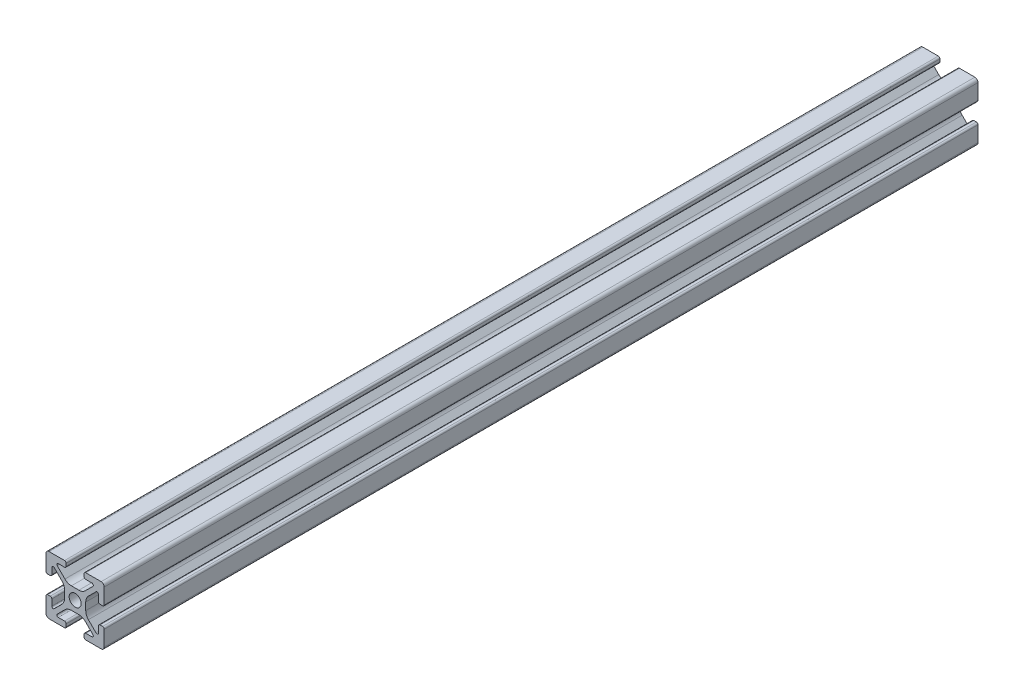
from build123d import *

# Parameters (mm, degrees)
SKETCH2_R           = 2.05
BOSS_EXTRUDE1_DEPTH = 300


with BuildPart() as part:
    # Sketch2 → Boss-Extrude1 (new body)
    with BuildSketch(Plane.XY):
        with BuildLine():
            Line((-3.642230561, 1.287773026), (-3.642230561, -1.287773026))
            ThreePointArc((-3.642230561, -1.287773026), (-3.87999308, -2.483085929), (-4.55708345, -3.496423279))
            Line((-4.55708345, -3.496423279), (-7.182004606, -6.121344434))
            ThreePointArc((-7.182004606, -6.121344434), (-7.704200045, -6.225215565), (-8, -5.782519648))
            Line((-8, -5.782519648), (-8, -3.622007668))
            ThreePointArc((-8, -3.622007668), (-8.161974206, -3.230967343), (-8.553014531, -3.068993137))
            Line((-8.553014531, -3.068993137), (-9.443284204, -3.068993137))
            ThreePointArc((-9.443284204, -3.068993137), (-9.836715763, -3.229656566), (-10, -3.622007668))
            Line((-10, -3.622007668), (-10, -8.939033256))
            ThreePointArc((-10, -8.939033256), (-9.689250035, -9.689250035), (-8.939033256, -10))
            Line((-8.939033256, -10), (-3.622007668, -10))
            ThreePointArc((-3.622007668, -10), (-3.229656566, -9.836715763), (-3.068993137, -9.443284204))
            Line((-3.068993137, -9.443284204), (-3.068993137, -8.553014531))
            ThreePointArc((-3.068993137, -8.553014531), (-3.230967343, -8.161974206), (-3.622007668, -8))
            Line((-3.622007668, -8), (-5.782519648, -8))
            ThreePointArc((-5.782519648, -8), (-6.225215565, -7.704200045), (-6.121344434, -7.182004606))
            Line((-6.121344434, -7.182004606), (-3.496423279, -4.55708345))
            ThreePointArc((-3.496423279, -4.55708345), (-2.483085929, -3.87999308), (-1.287773026, -3.642230561))
            Line((-1.287773026, -3.642230561), (1.287773026, -3.642230561))
            ThreePointArc((1.287773026, -3.642230561), (2.483085929, -3.87999308), (3.496423279, -4.55708345))
            Line((3.496423279, -4.55708345), (6.121344434, -7.182004606))
            ThreePointArc((6.121344434, -7.182004606), (6.225215565, -7.704200045), (5.782519648, -8))
            Line((5.782519648, -8), (3.622007668, -8))
            ThreePointArc((3.622007668, -8), (3.230967343, -8.161974206), (3.068993137, -8.553014531))
            Line((3.068993137, -8.553014531), (3.068993137, -9.443284204))
            ThreePointArc((3.068993137, -9.443284204), (3.229656566, -9.836715763), (3.622007668, -10))
            Line((3.622007668, -10), (8.939033256, -10))
            ThreePointArc((8.939033256, -10), (9.689250035, -9.689250035), (10, -8.939033256))
            Line((10, -8.939033256), (10, -3.622007668))
            ThreePointArc((10, -3.622007668), (9.836715763, -3.229656566), (9.443284204, -3.068993137))
            Line((9.443284204, -3.068993137), (8.553014531, -3.068993137))
            ThreePointArc((8.553014531, -3.068993137), (8.161974206, -3.230967343), (8, -3.622007668))
            Line((8, -3.622007668), (8, -5.782519648))
            ThreePointArc((8, -5.782519648), (7.704200045, -6.225215565), (7.182004606, -6.121344434))
            Line((7.182004606, -6.121344434), (4.55708345, -3.496423279))
            ThreePointArc((4.55708345, -3.496423279), (3.87999308, -2.483085929), (3.642230561, -1.287773026))
            Line((3.642230561, -1.287773026), (3.642230561, 1.287773026))
            ThreePointArc((3.642230561, 1.287773026), (3.87999308, 2.483085929), (4.55708345, 3.496423279))
            Line((4.55708345, 3.496423279), (7.182004606, 6.121344434))
            ThreePointArc((7.182004606, 6.121344434), (7.704200045, 6.225215565), (8, 5.782519648))
            Line((8, 5.782519648), (8, 3.622007668))
            ThreePointArc((8, 3.622007668), (8.161974206, 3.230967343), (8.553014531, 3.068993137))
            Line((8.553014531, 3.068993137), (9.443284204, 3.068993137))
            ThreePointArc((9.443284204, 3.068993137), (9.836715763, 3.229656566), (10, 3.622007668))
            Line((10, 3.622007668), (10, 8.939033256))
            ThreePointArc((10, 8.939033256), (9.689250035, 9.689250035), (8.939033256, 10))
            Line((8.939033256, 10), (3.622007668, 10))
            ThreePointArc((3.622007668, 10), (3.229656566, 9.836715763), (3.068993137, 9.443284204))
            Line((3.068993137, 9.443284204), (3.068993137, 8.553014531))
            ThreePointArc((3.068993137, 8.553014531), (3.230967343, 8.161974206), (3.622007668, 8))
            Line((3.622007668, 8), (5.782519648, 8))
            ThreePointArc((5.782519648, 8), (6.225215565, 7.704200045), (6.121344434, 7.182004606))
            Line((6.121344434, 7.182004606), (3.496423279, 4.55708345))
            ThreePointArc((3.496423279, 4.55708345), (2.483085929, 3.87999308), (1.287773026, 3.642230561))
            Line((1.287773026, 3.642230561), (-1.287773026, 3.642230561))
            ThreePointArc((-1.287773026, 3.642230561), (-2.483085929, 3.87999308), (-3.496423279, 4.55708345))
            Line((-3.496423279, 4.55708345), (-6.121344434, 7.182004606))
            ThreePointArc((-6.121344434, 7.182004606), (-6.225215565, 7.704200045), (-5.782519648, 8))
            Line((-5.782519648, 8), (-3.622007668, 8))
            ThreePointArc((-3.622007668, 8), (-3.230967343, 8.161974206), (-3.068993137, 8.553014531))
            Line((-3.068993137, 8.553014531), (-3.068993137, 9.443284204))
            ThreePointArc((-3.068993137, 9.443284204), (-3.229656566, 9.836715763), (-3.622007668, 10))
            Line((-3.622007668, 10), (-8.939033256, 10))
            ThreePointArc((-8.939033256, 10), (-9.689250035, 9.689250035), (-10, 8.939033256))
            Line((-10, 8.939033256), (-10, 3.622007668))
            ThreePointArc((-10, 3.622007668), (-9.836715763, 3.229656566), (-9.443284204, 3.068993137))
            Line((-9.443284204, 3.068993137), (-8.553014531, 3.068993137))
            ThreePointArc((-8.553014531, 3.068993137), (-8.161974206, 3.230967343), (-8, 3.622007668))
            Line((-8, 3.622007668), (-8, 5.782519648))
            ThreePointArc((-8, 5.782519648), (-7.704200045, 6.225215565), (-7.182004606, 6.121344434))
            Line((-7.182004606, 6.121344434), (-4.55708345, 3.496423279))
            ThreePointArc((-4.55708345, 3.496423279), (-3.87999308, 2.483085929), (-3.642230561, 1.287773026))
        make_face()
        Circle(SKETCH2_R, mode=Mode.SUBTRACT)
    extrude(amount=-BOSS_EXTRUDE1_DEPTH)


solid = part.part
